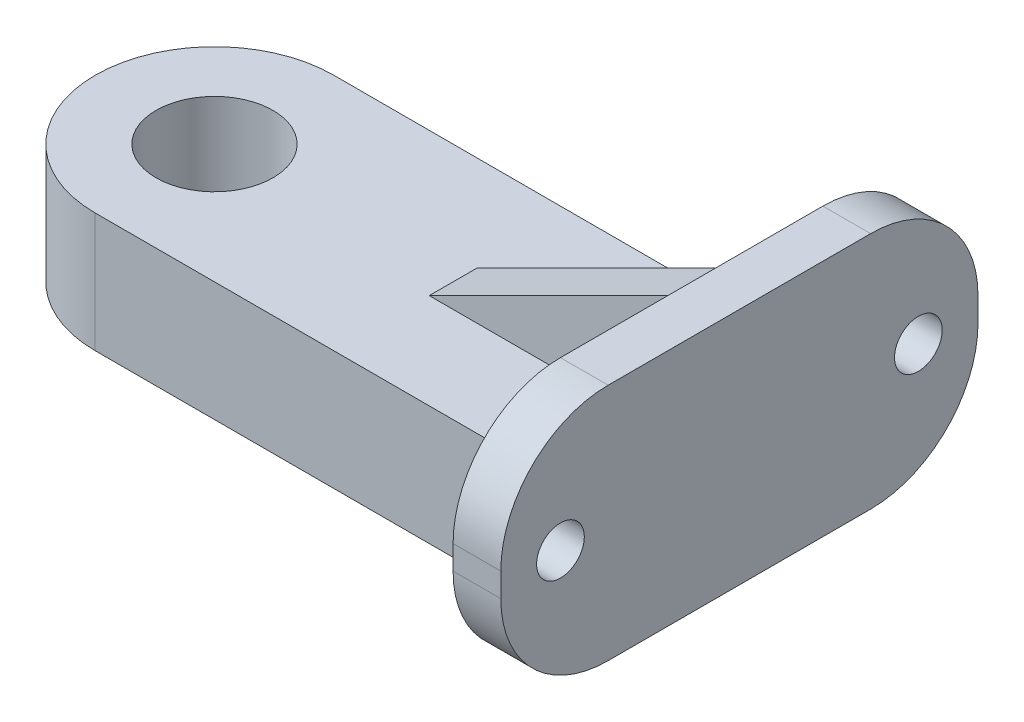
from build123d import *

# Parameters (mm, degrees)
SKETCH1_R           = 2.45
BOSS_EXTRUDE1_DEPTH = 5
SKETCH2_R           = 1
BOSS_EXTRUDE2_DEPTH = 2
BOSS_EXTRUDE3_DEPTH = 1


with BuildPart() as part:
    # Sketch1 → Boss-Extrude1 (new body)
    with BuildSketch(Plane(origin=(0, 0, 0), x_dir=(1, 0, 0), z_dir=(0, 1, 0))):
        with BuildLine():
            Line((0, 5), (20, 5))
            Line((20, 5), (20, -5))
            Line((20, -5), (0, -5))
            ThreePointArc((0, -5), (-5, 0), (0, 5))
        make_face()
        Circle(SKETCH1_R, mode=Mode.SUBTRACT)
    extrude(amount=BOSS_EXTRUDE1_DEPTH)

    # Sketch2 → Boss-Extrude2 (add)
    with BuildSketch(Plane(origin=(20, 0, 0), x_dir=(0, 0, -1), z_dir=(1, 0, 0))):
        with BuildLine():
            Line((-5.5, 10), (5.5, 10))
            ThreePointArc((5.5, 10), (8.681980515, 8.681980515), (10, 5.5))
            Line((10, 5.5), (10, 4.5))
            ThreePointArc((10, 4.5), (8.681980515, 1.318019485), (5.5, 0))
            Line((5.5, 0), (-5.5, 0))
            ThreePointArc((-5.5, 0), (-8.681980515, 1.318019485), (-10, 4.5))
            Line((-10, 4.5), (-10, 5.5))
            ThreePointArc((-10, 5.5), (-8.681980515, 8.681980515), (-5.5, 10))
        make_face()
        with Locations((-7.5, 5)):
            Circle(SKETCH2_R, mode=Mode.SUBTRACT)
        with Locations((7.5, 5)):
            Circle(SKETCH2_R, mode=Mode.SUBTRACT)
    extrude(amount=BOSS_EXTRUDE2_DEPTH)

    # Sketch3 → Boss-Extrude3 (add, symmetric)
    with BuildSketch(Plane.XY):
        Polygon((10, 5), (20, 10), (20, 5), align=None)
    extrude(amount=BOSS_EXTRUDE3_DEPTH, both=True)


solid = part.part
